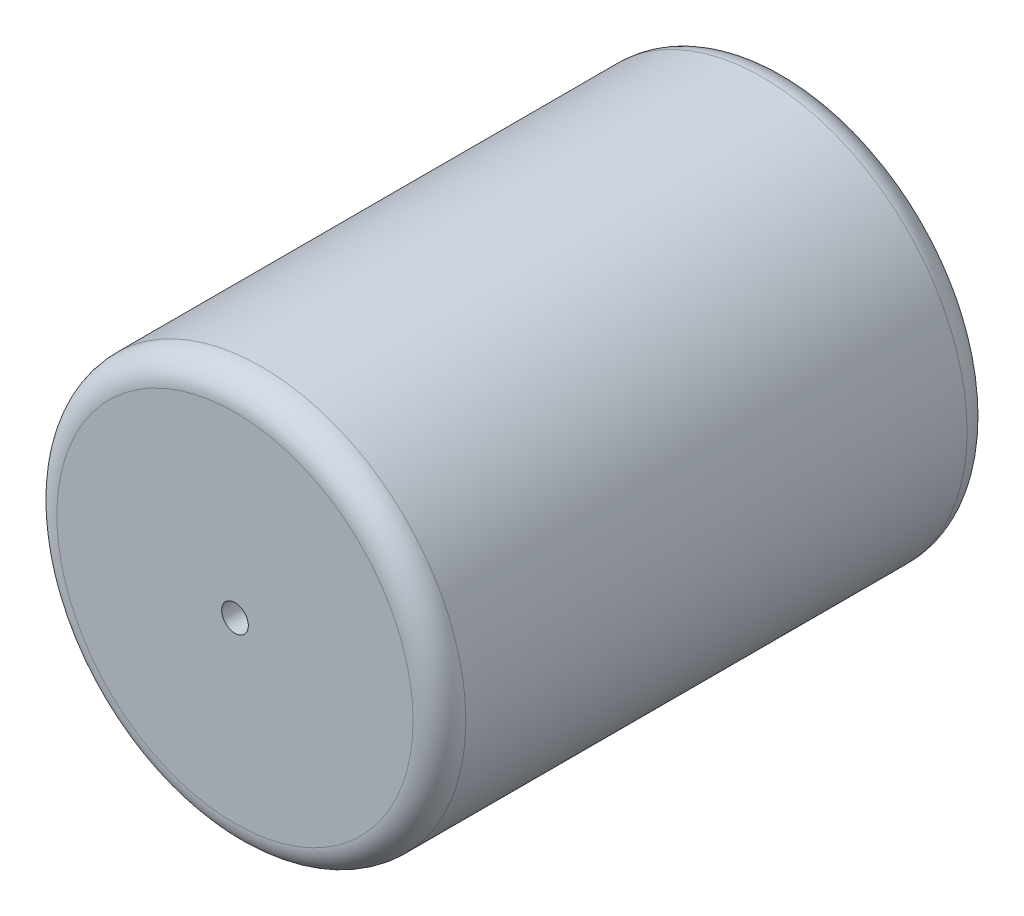
from build123d import *

# Parameters (mm, degrees)
SKETCH1_R           = 7.75
BOSS_EXTRUDE1_DEPTH = 21
FILLET1_R           = 1
SKETCH2_R           = 0.505
CUT_EXTRUDE1_DEPTH  = 51.7


with BuildPart() as part:
    # Sketch1 → Boss-Extrude1 (new body)
    with BuildSketch(Plane.XY):
        Circle(SKETCH1_R)
    extrude(amount=BOSS_EXTRUDE1_DEPTH)

    # Fillet1
    fillet1_edges = [part.edges().sort_by_distance(p)[0] for p in [
        (-7.75, 0, 0),
        (-7.75, 0, 21),
    ]]
    fillet(fillet1_edges, radius=FILLET1_R)

    # Sketch2 → Cut-Extrude1 (cut)
    with BuildSketch(Plane.XY.offset(21)):
        Circle(SKETCH2_R)
    extrude(amount=-CUT_EXTRUDE1_DEPTH, mode=Mode.SUBTRACT)


solid = part.part
